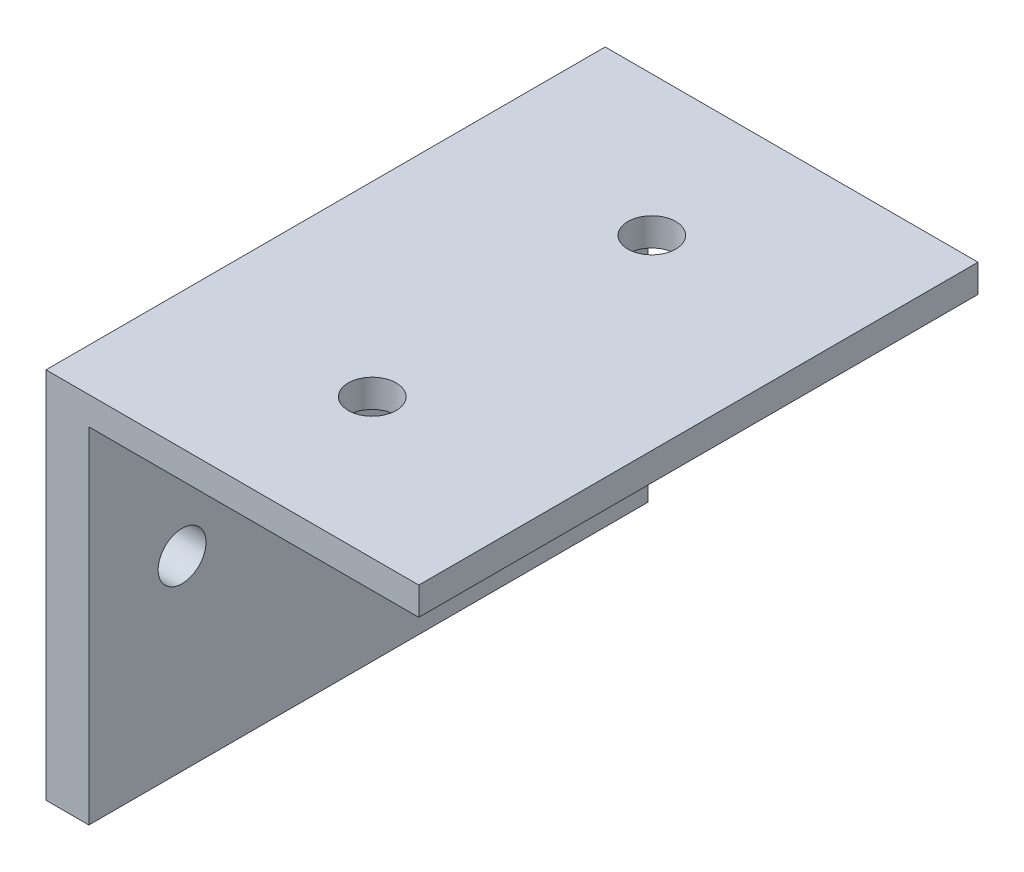
from build123d import *

# Parameters (mm, degrees)
BOSS_EXTRUDE1_DEPTH                    = 76.2
F_0_257_DIAMETER_HOLE1_D               = 6.5278
F_0_257_DIAMETER_HOLE1_DEPTH           = 5.842
F_0_257_DIAMETER_HOLE1_ON_FACE_2_D     = 6.5278
F_0_257_DIAMETER_HOLE1_ON_FACE_2_DEPTH = 5.842


with BuildPart() as part:
    # Sketch1 → Boss-Extrude1 (new body)
    with BuildSketch(Plane.XY):
        Polygon((0, 0), (0, 50.8), (50.8, 50.8), (50.8, 46.99), (5.842, 46.99), (5.842, 0), align=None)
    extrude(amount=BOSS_EXTRUDE1_DEPTH)

    # F (0.257) Diameter Hole1
    with Locations(Plane(origin=(0, 25.4, 12.7), x_dir=(0, 0, -1), z_dir=(-1, 0, 0))):
        with Locations((0, 0), (-50.8, 0)):
            Hole(F_0_257_DIAMETER_HOLE1_D / 2, depth=F_0_257_DIAMETER_HOLE1_DEPTH)

    # F (0.257) Diameter Hole1 on face 2
    with Locations(Plane(origin=(25.4, 50.8, 19.05), x_dir=(0, 0, 1), z_dir=(0, 1, 0))):
        with Locations((0, 0), (38.1, 0)):
            Hole(F_0_257_DIAMETER_HOLE1_ON_FACE_2_D / 2, depth=F_0_257_DIAMETER_HOLE1_ON_FACE_2_DEPTH)


solid = part.part
